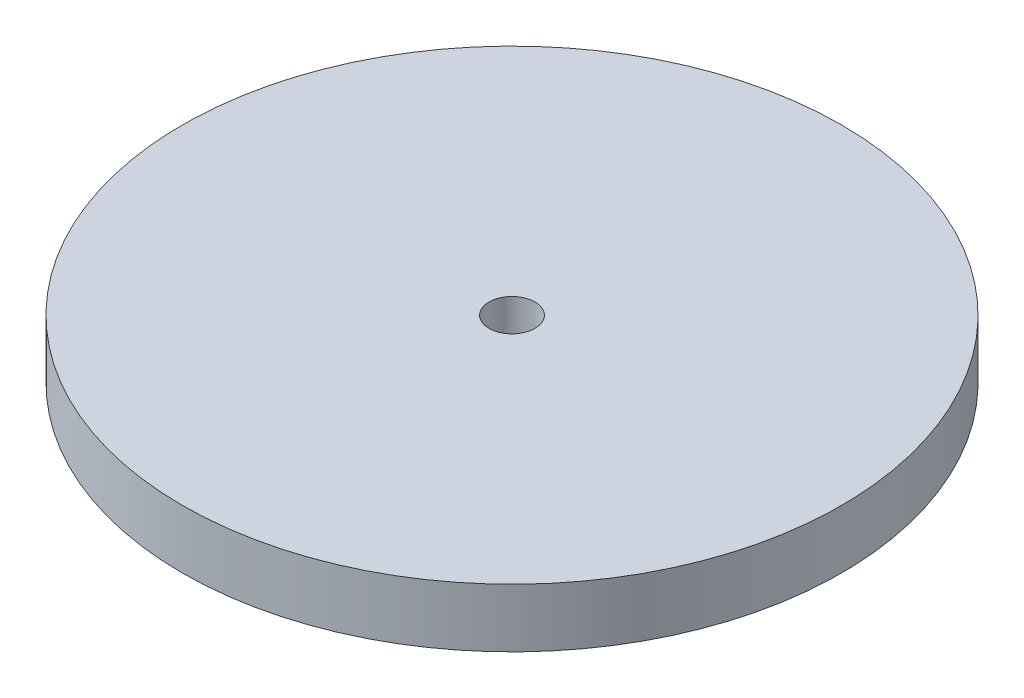
from build123d import *

# Parameters (mm, degrees)
SKETCH1_R           = 18
BOSS_EXTRUDE1_DEPTH = 3.2
SKETCH2_R           = 1.2525
CUT_EXTRUDE1_DEPTH  = 4.2


with BuildPart() as part:
    # Sketch1 → Boss-Extrude1 (new body)
    with BuildSketch(Plane(origin=(0, 0, 0), x_dir=(1, 0, 0), z_dir=(0, 1, 0))):
        Circle(SKETCH1_R)
    extrude(amount=BOSS_EXTRUDE1_DEPTH)

    # Sketch2 → Cut-Extrude1 (cut, through all)
    with BuildSketch(Plane(origin=(0, 3.2, 0), x_dir=(1, 0, 0), z_dir=(0, 1, 0))):
        Circle(SKETCH2_R)
    extrude(amount=-CUT_EXTRUDE1_DEPTH, mode=Mode.SUBTRACT)


solid = part.part
